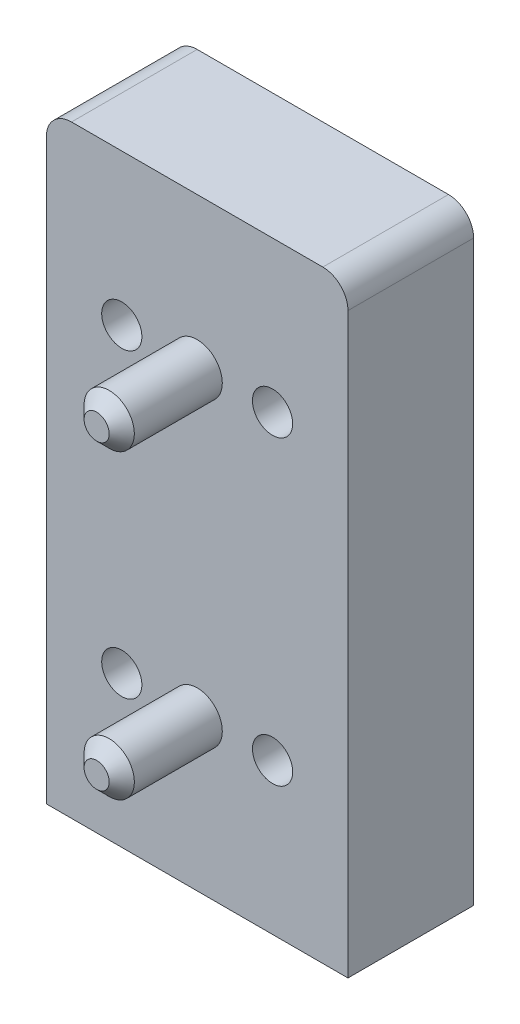
from build123d import *

# Parameters (mm, degrees)
BOSS_EXTRUDE1_DEPTH        = 10
SKETCH2_R                  = 1
CUT_EXTRUDE1_DEPTH         = 0.2
SKETCH3_R                  = 2
BOSS_EXTRUDE2_DEPTH        = 8
BOSS_EXTRUDE2_2_DEPTH      = 8
HOLE_WIZARD_M31_AT_2_COUNT = 2
HOLE_WIZARD_M31_AT_2_PITCH = 12
HOLE_WIZARD_M31_AT_3_COUNT = 2
HOLE_WIZARD_M31_AT_3_PITCH = 26.83281573
HOLE_WIZARD_M31_AT_4_COUNT = 2
HOLE_WIZARD_M31_AT_4_PITCH = 24
M3X0_51_AT_2_COUNT         = 2
M3X0_51_AT_2_PITCH         = 8.500304995
M3X0_51_AT_3_COUNT         = 2
M3X0_51_AT_3_PITCH         = 16.593287348
M3X0_51_AT_4_COUNT         = 2
M3X0_51_AT_4_PITCH         = 14
M3X0_51_AT_5_COUNT         = 2
M3X0_51_AT_5_PITCH         = 22.022715546
M3X0_51_AT_6_COUNT         = 2
M3X0_51_AT_6_PITCH         = 17
M3X0_51_AT_7_COUNT         = 2
M3X0_51_AT_7_PITCH         = 22.259900831
M3X0_51_AT_8_COUNT         = 2
M3X0_51_AT_8_PITCH         = 26.430762096
CHAMFER_1_SIZE             = 1
CHAMFER_2_SIZE             = 1


with BuildPart() as part:
    # Sketch1 → Boss-Extrude1 (new body)
    with BuildSketch(Plane.XY):
        with BuildLine():
            Line((-12, -36), (12, -36))
            Line((12, -36), (12, 10))
            ThreePointArc((12, 10), (11.414213562, 11.414213562), (10, 12))
            Line((10, 12), (-10, 12))
            ThreePointArc((-10, 12), (-11.414213562, 11.414213562), (-12, 10))
            Line((-12, 10), (-12, -36))
        make_face()
    extrude(amount=BOSS_EXTRUDE1_DEPTH)

    # Sketch2 → Cut-Extrude1 (cut)
    with BuildSketch(Plane(origin=(0, 0, 0), x_dir=(-1, 0, 0), z_dir=(0, 0, -1))):
        with Locations((4, 8)):
            Circle(SKETCH2_R)
        with Locations((-9.027, -24.116)):
            Circle(SKETCH2_R)
        with BuildLine():
            Line((-2.14, -2.16), (2.14, -2.16))
            ThreePointArc((2.14, -2.16), (2.993553391, -2.513553391), (2.64, -1.66))
            Line((2.64, -1.66), (2.64, 1.66))
            ThreePointArc((2.64, 1.66), (2.993553391, 2.513553391), (2.14, 2.16))
            Line((2.14, 2.16), (-2.14, 2.16))
            ThreePointArc((-2.14, 2.16), (-2.993553391, 2.513553391), (-2.64, 1.66))
            Line((-2.64, 1.66), (-2.64, -1.66))
            ThreePointArc((-2.64, -1.66), (-2.993553391, -2.513553391), (-2.14, -2.16))
        make_face()
        with BuildLine():
            Line((2.26, -25.76), (2.26, -22.24))
            ThreePointArc((2.26, -22.24), (2.613553391, -21.386446609), (1.76, -21.74))
            Line((1.76, -21.74), (-1.76, -21.74))
            ThreePointArc((-1.76, -21.74), (-2.613553391, -21.386446609), (-2.26, -22.24))
            Line((-2.26, -22.24), (-2.26, -25.76))
            ThreePointArc((-2.26, -25.76), (-2.613553391, -26.613553391), (-1.76, -26.26))
            Line((-1.76, -26.26), (1.76, -26.26))
            ThreePointArc((1.76, -26.26), (2.613553391, -26.613553391), (2.26, -25.76))
        make_face()
    extrude(amount=-CUT_EXTRUDE1_DEPTH, mode=Mode.SUBTRACT)

    # Sketch7 → Зенковка для  винта с полупотайной головкой M31 (revolve, cut)
    with BuildSketch(Plane.YZ.offset(-6)):
        Polygon((0, 0), (0, 18), (1.6, 18), (1.6, 1.55), (3.15, 0), align=None)
    hole_wizard_m31 = revolve(axis=Axis((-6, 0, -6.35), (0, 0, 1)), mode=Mode.SUBTRACT)

    # Зенковка для  винта с полупотайной головкой M31 at 2: Зенковка для  винта с полупотайной головкой M31 ×2
    with Locations(*[(i * HOLE_WIZARD_M31_AT_2_PITCH, 0, 0) for i in range(1, HOLE_WIZARD_M31_AT_2_COUNT)]):
        add(hole_wizard_m31, mode=Mode.SUBTRACT)

    # Зенковка для  винта с полупотайной головкой M31 at 3: Зенковка для  винта с полупотайной головкой M31 ×2
    with Locations(*[Vector(0.447213595, -0.894427191, 0) * (i * HOLE_WIZARD_M31_AT_3_PITCH) for i in range(1, HOLE_WIZARD_M31_AT_3_COUNT)]):
        add(hole_wizard_m31, mode=Mode.SUBTRACT)

    # Зенковка для  винта с полупотайной головкой M31 at 4: Зенковка для  винта с полупотайной головкой M31 ×2
    with Locations(*[(0, -i * HOLE_WIZARD_M31_AT_4_PITCH, 0) for i in range(1, HOLE_WIZARD_M31_AT_4_COUNT)]):
        add(hole_wizard_m31, mode=Mode.SUBTRACT)

    # Эскиз1 → Отверстие обработанное метчиком M3x0.51 (revolve, cut)
    with BuildSketch(Plane(origin=(6.5, -9, 0), x_dir=(0, 1, 0), z_dir=(1, 0, 0))):
        Polygon((0, 0), (0, 7.251075774), (1.25, 6.5), (1.25, 0), align=None)
    m3x0_51 = revolve(axis=Axis((6.5, -9, -6.35), (0, 0, 1)), mode=Mode.SUBTRACT)

    # Отверстие обработанное метчиком M3x0.51 at 2: Отверстие обработанное метчиком M3x0.51 ×2
    with Locations(*[Vector(0.297283451, -0.95478927, 0) * (i * M3X0_51_AT_2_PITCH) for i in range(1, M3X0_51_AT_2_COUNT)]):
        add(m3x0_51, mode=Mode.SUBTRACT)

    # Отверстие обработанное метчиком M3x0.51 at 3: Отверстие обработанное метчиком M3x0.51 ×2
    with Locations(*[Vector(-0.872220175, -0.489113449, 0) * (i * M3X0_51_AT_3_PITCH) for i in range(1, M3X0_51_AT_3_COUNT)]):
        add(m3x0_51, mode=Mode.SUBTRACT)

    # Отверстие обработанное метчиком M3x0.51 at 4: Отверстие обработанное метчиком M3x0.51 ×2
    with Locations(*[(-i * M3X0_51_AT_4_PITCH, 0, 0) for i in range(1, M3X0_51_AT_4_COUNT)]):
        add(m3x0_51, mode=Mode.SUBTRACT)

    # Отверстие обработанное метчиком M3x0.51 at 5: Отверстие обработанное метчиком M3x0.51 ×2
    with Locations(*[Vector(-0.635707253, 0.771930236, 0) * (i * M3X0_51_AT_5_PITCH) for i in range(1, M3X0_51_AT_5_COUNT)]):
        add(m3x0_51, mode=Mode.SUBTRACT)

    # Отверстие обработанное метчиком M3x0.51 at 6: Отверстие обработанное метчиком M3x0.51 ×2
    with Locations(*[(0, i * M3X0_51_AT_6_PITCH, 0) for i in range(1, M3X0_51_AT_6_COUNT)]):
        add(m3x0_51, mode=Mode.SUBTRACT)

    # Отверстие обработанное метчиком M3x0.51 at 7: Отверстие обработанное метчиком M3x0.51 ×2
    with Locations(*[Vector(0.113522518, -0.993535424, 0) * (i * M3X0_51_AT_7_PITCH) for i in range(1, M3X0_51_AT_7_COUNT)]):
        add(m3x0_51, mode=Mode.SUBTRACT)

    # Отверстие обработанное метчиком M3x0.51 at 8: Отверстие обработанное метчиком M3x0.51 ×2
    with Locations(*[Vector(-0.547581638, -0.836752263, 0) * (i * M3X0_51_AT_8_PITCH) for i in range(1, M3X0_51_AT_8_COUNT)]):
        add(m3x0_51, mode=Mode.SUBTRACT)


with BuildPart() as body_2:
    # Sketch3 → Boss-Extrude2 (new body)
    with BuildSketch(Plane.XY.offset(10)):
        Circle(SKETCH3_R)
    extrude(amount=BOSS_EXTRUDE2_DEPTH)

    # Фаска1
    chamfer_1_edges = [body_2.edges().sort_by_distance(p)[0] for p in [
        (-2, 0, 18),
    ]]
    chamfer(chamfer_1_edges, length=CHAMFER_1_SIZE)


with BuildPart() as body_3:
    # Sketch3 → Boss-Extrude2 2 (new body)
    with BuildSketch(Plane.XY.offset(10)):
        with Locations((0, -24)):
            Circle(SKETCH3_R)
    extrude(amount=BOSS_EXTRUDE2_2_DEPTH)

    # Фаска2
    chamfer_2_edges = [body_3.edges().sort_by_distance(p)[0] for p in [
        (-2, -24, 18),
    ]]
    chamfer(chamfer_2_edges, length=CHAMFER_2_SIZE)


solid = Compound([part.part, body_2.part, body_3.part])
